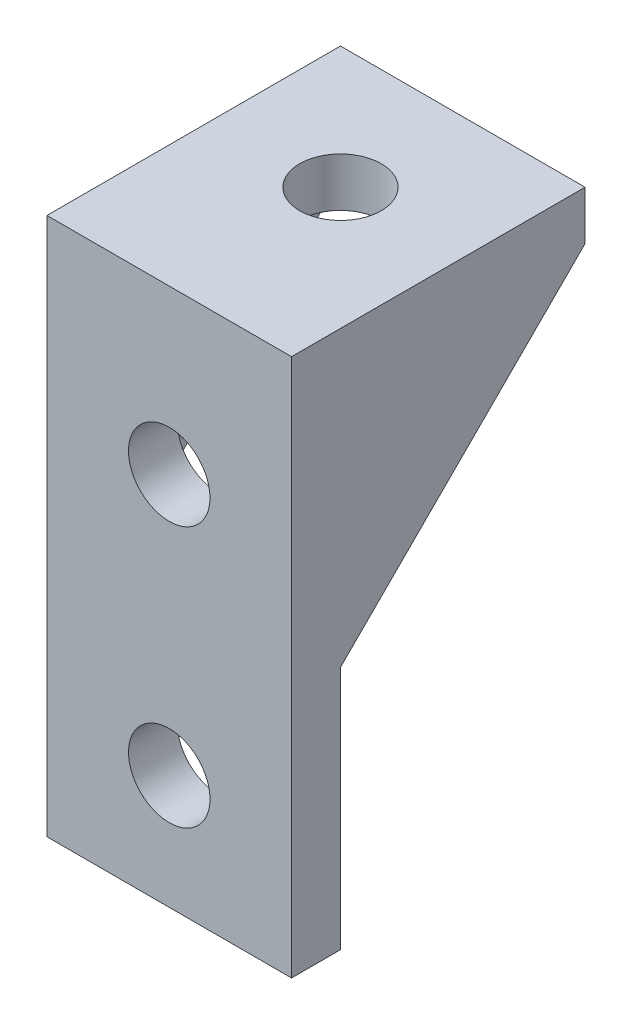
from build123d import *

# Parameters (mm, degrees)
SKETCH1_W           = 15
SKETCH1_H           = 30
SKETCH1_R           = 2.5
BOSS_EXTRUDE1_DEPTH = 3
SKETCH2_W           = 15
SKETCH2_H           = 18
SKETCH2_R           = 2.5
BOSS_EXTRUDE2_DEPTH = 3
BOSS_EXTRUDE3_DEPTH = 2


with BuildPart() as part:
    # Sketch1 → Boss-Extrude1 (new body)
    with BuildSketch(Plane.XY):
        Rectangle(SKETCH1_W, SKETCH1_H)
        with Locations((0, 8)):
            Circle(SKETCH1_R, mode=Mode.SUBTRACT)
        with Locations((0, -8)):
            Circle(SKETCH1_R, mode=Mode.SUBTRACT)
    extrude(amount=BOSS_EXTRUDE1_DEPTH)

    # Sketch2 → Boss-Extrude2 (add)
    with BuildSketch(Plane(origin=(0, 15, 0), x_dir=(1, 0, 0), z_dir=(0, 1, 0))):
        with Locations((0, 6)):
            Rectangle(SKETCH2_W, SKETCH2_H)
        with Locations((0, 7.5)):
            Circle(SKETCH2_R, mode=Mode.SUBTRACT)
    extrude(amount=BOSS_EXTRUDE2_DEPTH)

    # Sketch3 → Boss-Extrude3 (add)
    with BuildSketch(Plane(origin=(7.5, 0, 0), x_dir=(0, 0, -1), z_dir=(1, 0, 0))):
        Polygon((15, 15), (0, 0), (0, 15), align=None)
    boss_extrude3 = extrude(amount=-BOSS_EXTRUDE3_DEPTH)

    # Mirror1: Boss-Extrude3 across plane
    add(boss_extrude3.mirror(Plane(origin=(0, 0, 0), x_dir=(0, 0, 1), z_dir=(1, 0, 0))))


solid = part.part
